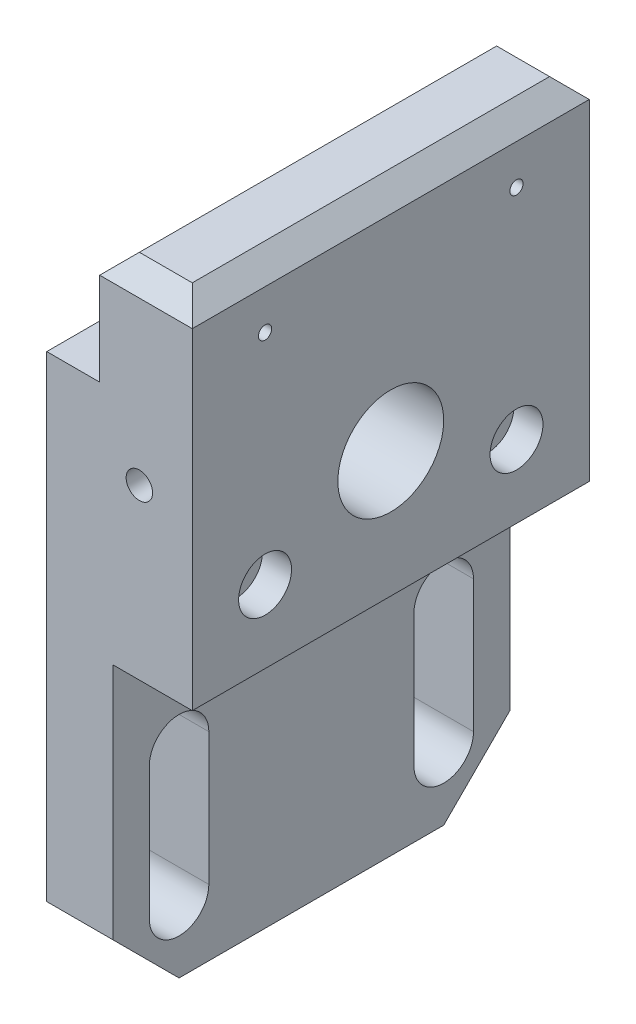
from build123d import *

# Parameters (mm, degrees)
EXTRUDE_1_DEPTH              = 30
CUT_EXTRUDE_1_DEPTH          = 23
HOLE_WIZARD_M4_1_D           = 4.5
HOLE_WIZARD_M4_1_CBORE_D     = 8
HOLE_WIZARD_M4_1_CBORE_DEPTH = 4.4
SKETCH_6_R                   = 5
CUT_EXTRUDE_2_DEPTH          = 9
SKETCH_7_R                   = 8
CUT_EXTRUDE_3_DEPTH          = 23
HOLE_WIZARD_M4_1_2_D         = 2
HOLE_WIZARD_M4_2_D           = 4
CHAMFER_1_SIZE               = 10
CHAMFER_2_SIZE               = 3


with BuildPart() as part:
    # 스케치1 → 보스-돌출1 (new body, symmetric)
    with BuildSketch(Plane.XY):
        Polygon((0, 0), (0, 82), (8, 82), (8, 99), (22, 99), (22, 46), (10, 46), (10, 0), align=None)
    extrude(amount=EXTRUDE_1_DEPTH, both=True)

    # 스케치2 → 컷-돌출1 (cut, through all)
    with BuildSketch(Plane.ZY):
        with BuildLine():
            Line((-15.5, 30), (-15.5, 10))
            ThreePointArc((-15.5, 10), (-20, 5.5), (-24.5, 10))
            Line((-24.5, 10), (-24.5, 30))
            ThreePointArc((-24.5, 30), (-20, 34.5), (-15.5, 30))
        make_face()
        with BuildLine():
            Line((15.5, 30), (15.5, 10))
            ThreePointArc((15.5, 10), (20, 5.5), (24.5, 10))
            Line((24.5, 10), (24.5, 30))
            ThreePointArc((24.5, 30), (20, 34.5), (15.5, 30))
        make_face()
    extrude(amount=-CUT_EXTRUDE_1_DEPTH, mode=Mode.SUBTRACT)

    # Hole Wizard M4 _ _ _ _ _1 (through all)
    with Locations(Plane(origin=(22, 0, 0), x_dir=(0, 0, -1), z_dir=(1, 0, 0))):
        with Locations((-19, 57), (19, 57)):
            CounterBoreHole(HOLE_WIZARD_M4_1_D / 2, HOLE_WIZARD_M4_1_CBORE_D / 2, HOLE_WIZARD_M4_1_CBORE_DEPTH)

    # 스케치6 → 컷-돌출2 (cut)
    with BuildSketch(Plane.ZY):
        with Locations((-19, 57)):
            Circle(SKETCH_6_R)
        with Locations((19, 57)):
            Circle(SKETCH_6_R)
    extrude(amount=-CUT_EXTRUDE_2_DEPTH, mode=Mode.SUBTRACT)

    # 스케치7 → 컷-돌출3 (cut, through all)
    with BuildSketch(Plane(origin=(22, 0, 0), x_dir=(0, 0, -1), z_dir=(1, 0, 0))):
        with Locations((0, 65)):
            Circle(SKETCH_7_R)
    extrude(amount=-CUT_EXTRUDE_3_DEPTH, mode=Mode.SUBTRACT)

    # Hole Wizard M4 _ _1 2 (through all)
    with Locations(Plane(origin=(22, 0, 0), x_dir=(0, 0, -1), z_dir=(1, 0, 0))):
        with Locations((-19, 90), (19, 90)):
            Hole(HOLE_WIZARD_M4_1_2_D / 2)

    # M4 여유 구멍2 (through all)
    with Locations(Plane.XY.offset(30)):
        with Locations((14, 71.5)):
            Hole(HOLE_WIZARD_M4_2_D / 2)

    # 모따기1
    chamfer_1_edges = [part.edges().sort_by_distance(p)[0] for p in [
        (5, 0, -30),
        (5, 0, 30),
    ]]
    chamfer(chamfer_1_edges, length=CHAMFER_1_SIZE)

    # 모따기2
    chamfer_2_edges = [part.edges().sort_by_distance(p)[0] for p in [
        (8, 99, 0),
        (22, 99, 0),
        (15, 99, 30),
        (15, 99, -30),
    ]]
    chamfer(chamfer_2_edges, length=CHAMFER_2_SIZE)


solid = part.part
